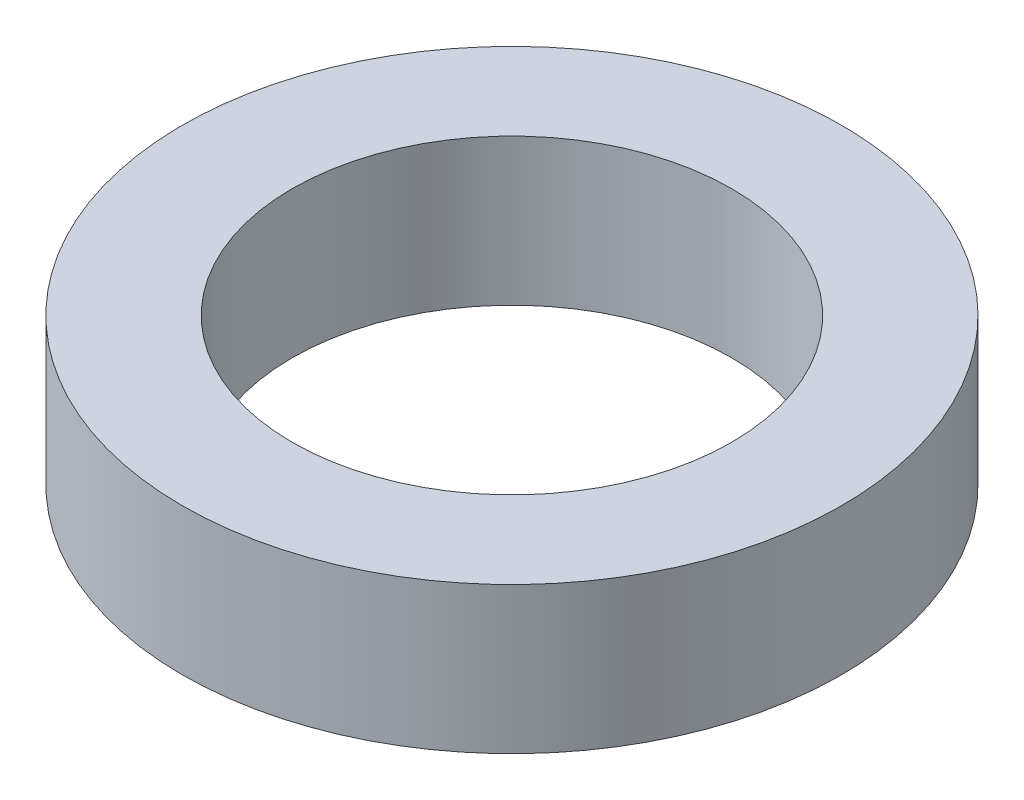
from build123d import *

# Parameters (mm, degrees)
SKETCH1_R           = 9
SKETCH1_R_2         = 6
BOSS_EXTRUDE1_DEPTH = 4


with BuildPart() as part:
    # Sketch1 → Boss-Extrude1 (new body)
    with BuildSketch(Plane(origin=(0, 0, 0), x_dir=(1, 0, 0), z_dir=(0, 1, 0))):
        Circle(SKETCH1_R)
        Circle(SKETCH1_R_2, mode=Mode.SUBTRACT)
    extrude(amount=BOSS_EXTRUDE1_DEPTH)


solid = part.part
